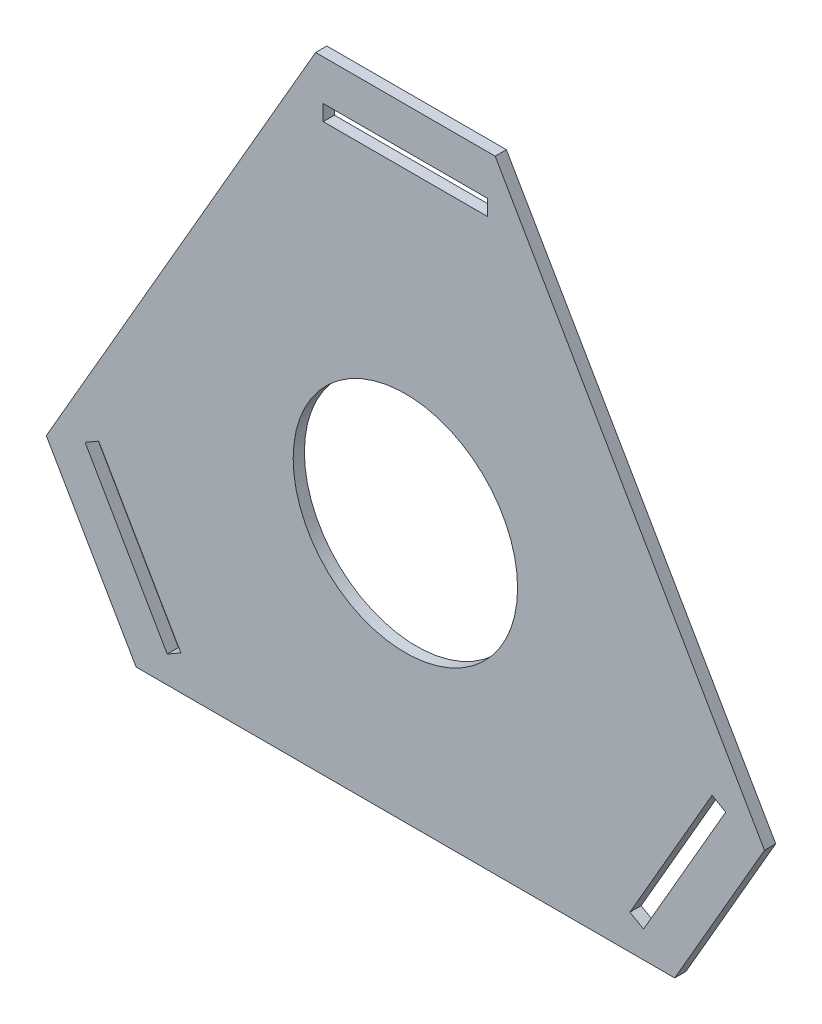
from build123d import *

# Parameters (mm, degrees)
SKETCH1_R           = 50
BOSS_EXTRUDE1_DEPTH = 5


with BuildPart() as part:
    # Sketch1 → Boss-Extrude1 (new body)
    with BuildSketch(Plane.XY):
        Polygon((0, 0), (240, 0), (280, 69.282032303), (160, 277.128129211), (80, 277.128129211), (-40, 69.282032303), align=None)
        with Locations((120, 115.470053838)):
            Circle(SKETCH1_R, mode=Mode.SUBTRACT)
        Polygon((149.607695155, 259.128129211), (90.392304845, 259.128129211), (83.392304845, 259.128129211), (83.392304845, 252.128129211), (90.392304845, 252.128129211), (94.43375673, 252.128129211), (145.56624327, 252.128129211), (149.607695155, 252.128129211), (156.607695155, 252.128129211), (156.607695155, 259.128129211), align=None, mode=Mode.SUBTRACT)
        Polygon((225.56624327, 25), (251.132486541, 69.282032303), (253.153212483, 72.782032303), (256.653212483, 78.844210129), (262.715390309, 75.344210129), (259.215390309, 69.282032303), (229.607695155, 18), (226.107695155, 11.937822174), (220.045517328, 15.437822174), (223.545517328, 21.5), align=None, mode=Mode.SUBTRACT)
        Polygon((-11.132486541, 69.282032303), (14.43375673, 25), (16.454482672, 21.5), (19.954482672, 15.437822174), (13.892304845, 11.937822174), (10.392304845, 18), (-19.215390309, 69.282032303), (-22.715390309, 75.344210129), (-16.653212483, 78.844210129), (-13.153212483, 72.782032303), align=None, mode=Mode.SUBTRACT)
    extrude(amount=BOSS_EXTRUDE1_DEPTH)


solid = part.part
